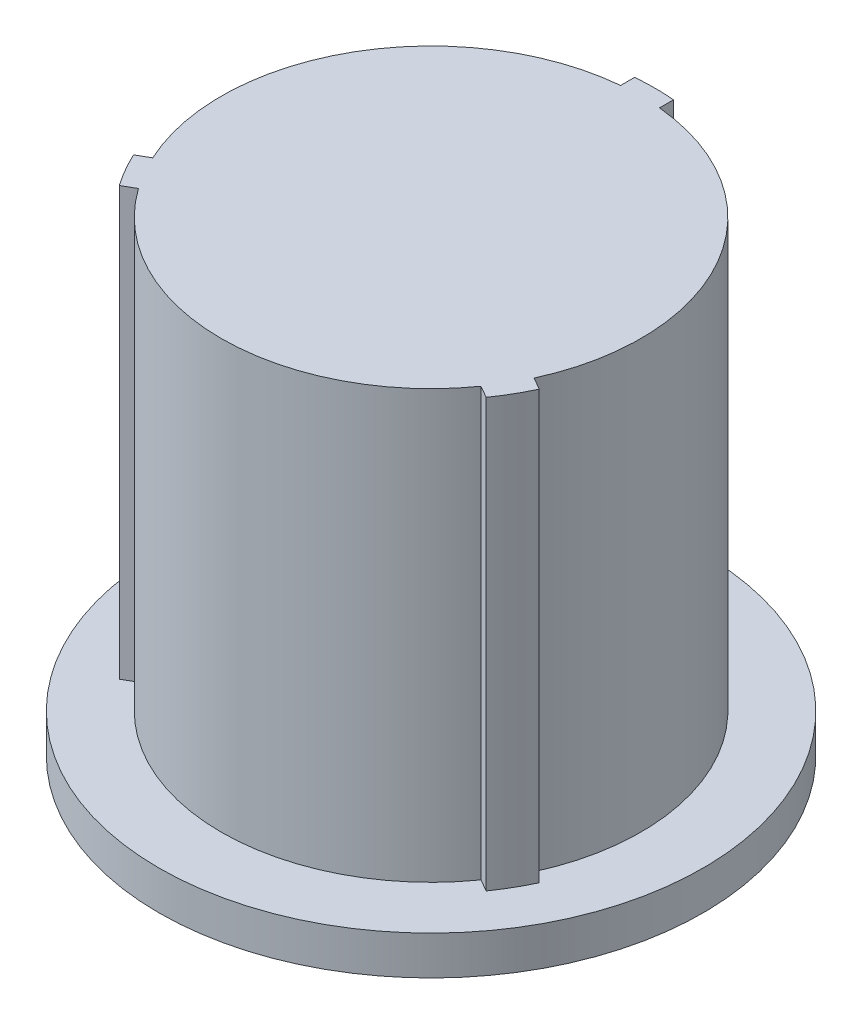
from build123d import *

# Parameters (mm, degrees)
BOSS_EXTRUDE1_DEPTH = 19.05
SKETCH6_W           = 0.608326788
SKETCH6_H           = 1.5875
SKETCH8_W           = 2.576826788
SKETCH8_H           = 1.5875


with BuildPart() as part:
    # Sketch1 → Boss-Extrude1 (new body)
    with BuildSketch(Plane(origin=(0, 0, 0), x_dir=(1, 0, 0), z_dir=(0, 1, 0))):
        with BuildLine():
            Line((-0.79375, 9.109483901), (-0.79375, 8.535673212))
            ThreePointArc((-0.79375, 8.535673212), (-7.424002774, 4.28625), (-7.78898484, -3.580428942))
            Line((-7.78898484, -3.580428942), (-8.285919473, -3.867334286))
            ThreePointArc((-8.285919473, -3.867334286), (-7.918936292, -4.572), (-7.492169473, -5.242149615))
            Line((-7.492169473, -5.242149615), (-6.99523484, -4.95524427))
            ThreePointArc((-6.99523484, -4.95524427), (0, -8.5725), (6.99523484, -4.95524427))
            Line((6.99523484, -4.95524427), (7.492169473, -5.242149615))
            ThreePointArc((7.492169473, -5.242149615), (7.918936292, -4.572), (8.285919473, -3.867334286))
            Line((8.285919473, -3.867334286), (7.78898484, -3.580428942))
            ThreePointArc((7.78898484, -3.580428942), (7.424002774, 4.28625), (0.79375, 8.535673212))
            Line((0.79375, 8.535673212), (0.79375, 9.109483901))
            ThreePointArc((0.79375, 9.109483901), (0, 9.144), (-0.79375, 9.109483901))
        make_face()
    extrude(amount=BOSS_EXTRUDE1_DEPTH)

    # Sketch6 → Cut-Revolve2 (revolve, cut)
    with BuildSketch(Plane(origin=(0, 0, 0), x_dir=(0, 0, -1), z_dir=(1, 0, 0))):
        with Locations((8.839836606, 0.79375)):
            Rectangle(SKETCH6_W, SKETCH6_H)
    revolve(axis=Axis((0, 19.730213777, 0), (0, -1, 0)), mode=Mode.SUBTRACT)

    # Sketch8 → Revolve2 (revolve)
    with BuildSketch(Plane(origin=(0, 0, 0), x_dir=(0, 0, -1), z_dir=(1, 0, 0))):
        with Locations((9.824086606, 0.79375)):
            Rectangle(SKETCH8_W, SKETCH8_H)
    revolve(axis=Axis((0, 4.48386458, 0), (0, -1, 0)))


solid = part.part
